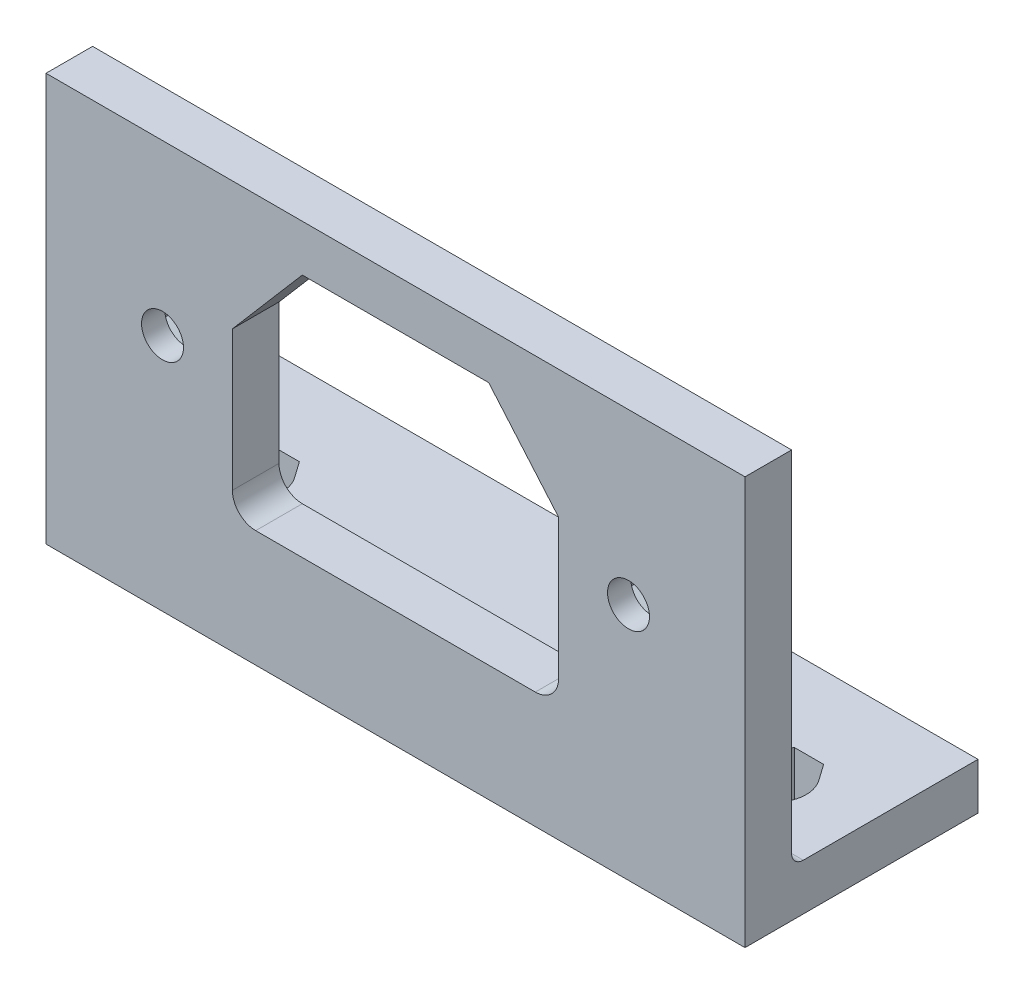
from build123d import *

# Parameters (mm, degrees)
SALIENTE_EXTRUIR1_DEPTH = 30
CROQUIS2_R              = 1.8
CORTAR_EXTRUIR1_DEPTH   = 21
CORTAR_EXTRUIR2_DEPTH   = 36
REDONDEO1_R             = 1
CORTAR_EXTRUIR3_DEPTH   = 2


with BuildPart() as part:
    # Croquis1 → Saliente-Extruir1 (new body, symmetric)
    with BuildSketch(Plane(origin=(0, 0, 0), x_dir=(0, 0, -1), z_dir=(1, 0, 0))):
        Polygon((0, 0), (0, 35), (4, 35), (4, 4), (20, 4), (20, 0), align=None)
    extrude(amount=SALIENTE_EXTRUIR1_DEPTH, both=True)

    # Croquis2 → Cortar-Extruir1 (cut, through all)
    with BuildSketch(Plane.XY):
        with Locations((-20, 20.5)):
            Circle(CROQUIS2_R)
        with Locations((20, 20.5)):
            Circle(CROQUIS2_R)
        with BuildLine():
            Line((-12, 10), (12, 10))
            ThreePointArc((12, 10), (13.414213562, 10.585786438), (14, 12))
            Line((14, 12), (14, 24))
            Line((14, 24), (8, 31))
            Line((8, 31), (-8, 31))
            Line((-8, 31), (-14, 24))
            Line((-14, 24), (-14, 12))
            ThreePointArc((-14, 12), (-13.414213562, 10.585786438), (-12, 10))
        make_face()
    extrude(amount=-CORTAR_EXTRUIR1_DEPTH, mode=Mode.SUBTRACT)

    # Croquis3 → Cortar-Extruir2 (cut, through all)
    with BuildSketch(Plane.XZ):
        with BuildLine():
            Line((-24.747814832, -11.58424382), (-23.75, -13))
            Line((-23.75, -13), (-21.25, -13))
            Line((-21.25, -13), (-20.252185168, -11.58424382))
            ThreePointArc((-20.252185168, -11.58424382), (-22.5, -7.25), (-24.747814832, -11.58424382))
        make_face()
        with BuildLine():
            Line((20.252185168, -11.58424382), (21.25, -13))
            Line((21.25, -13), (23.75, -13))
            Line((23.75, -13), (24.747814832, -11.58424382))
            ThreePointArc((24.747814832, -11.58424382), (22.5, -7.25), (20.252185168, -11.58424382))
        make_face()
    extrude(amount=-CORTAR_EXTRUIR2_DEPTH, mode=Mode.SUBTRACT)

    # Redondeo1
    redondeo1_edges = [part.edges().sort_by_distance(p)[0] for p in [
        (0, 4, -4),
    ]]
    fillet(redondeo1_edges, radius=REDONDEO1_R)

    # Croquis4 → Cortar-Extruir3 (cut)
    with BuildSketch(Plane(origin=(0, 0, -4), x_dir=(-1, 0, 0), z_dir=(0, 0, -1))):
        Polygon((-17, 18.767949192), (-17, 22.232050808), (-20, 23.964101615), (-23, 22.232050808), (-23, 18.767949192), (-20, 17.035898385), align=None)
        Polygon((17, 18.767949192), (20, 17.035898385), (23, 18.767949192), (23, 22.232050808), (20, 23.964101615), (17, 22.232050808), align=None)
    extrude(amount=-CORTAR_EXTRUIR3_DEPTH, mode=Mode.SUBTRACT)


solid = part.part
